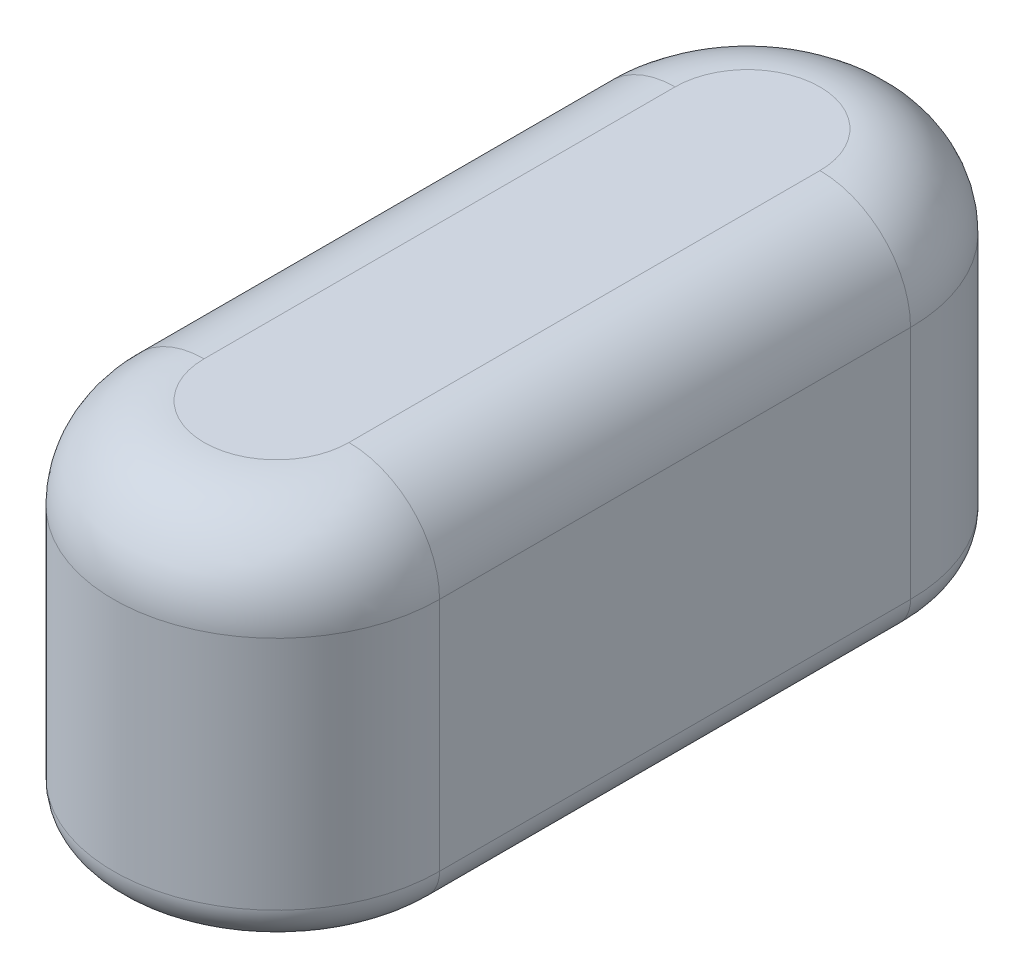
from build123d import *

# Parameters (mm, degrees)
BOSS_EXTRUDE1_DEPTH  = 330.2
REVOLVE1_ANGLE       = 90
MIRROR2_COPY_1_DEPTH = 330.2
MIRROR2_COPY_2_ANGLE = 90


with BuildPart() as part:
    # Sketch1 → Boss-Extrude1 (new body)
    with BuildSketch(Plane.XY):
        with BuildLine():
            Line((0, 12.7), (177.8, 12.7))
            ThreePointArc((177.8, 12.7), (204.740768363, 23.859231637), (215.9, 50.8))
            Line((215.9, 50.8), (215.9, 381))
            ThreePointArc((215.9, 381), (182.42230509, 461.82230509), (101.6, 495.3))
            Line((101.6, 495.3), (0, 495.3))
            Line((0, 495.3), (0, 508))
            Line((0, 508), (101.6, 508))
            ThreePointArc((101.6, 508), (191.402561211, 470.802561211), (228.6, 381))
            Line((228.6, 381), (228.6, 50.8))
            ThreePointArc((228.6, 50.8), (213.721024484, 14.878975516), (177.8, 0))
            Line((177.8, 0), (0, 0))
            Line((0, 0), (0, 12.7))
        make_face()
    boss_extrude1 = extrude(amount=BOSS_EXTRUDE1_DEPTH)

    # Sketch1_2 → Revolve1 (revolve)
    with BuildSketch(Plane.XY):
        with BuildLine():
            Line((0, 12.7), (177.8, 12.7))
            ThreePointArc((177.8, 12.7), (204.740768363, 23.859231637), (215.9, 50.8))
            Line((215.9, 50.8), (215.9, 381))
            ThreePointArc((215.9, 381), (182.42230509, 461.82230509), (101.6, 495.3))
            Line((101.6, 495.3), (0, 495.3))
            Line((0, 495.3), (0, 508))
            Line((0, 508), (101.6, 508))
            ThreePointArc((101.6, 508), (191.402561211, 470.802561211), (228.6, 381))
            Line((228.6, 381), (228.6, 50.8))
            ThreePointArc((228.6, 50.8), (213.721024484, 14.878975516), (177.8, 0))
            Line((177.8, 0), (0, 0))
            Line((0, 0), (0, 12.7))
        make_face()
    revolve1 = revolve(axis=Axis((0, 0, 0), (0, 1, 0)), revolution_arc=REVOLVE1_ANGLE)

    # Mirror1: Boss-Extrude1, Revolve1 across plane
    add(boss_extrude1.mirror(Plane(origin=(0, 0, 0), x_dir=(0, 0, 1), z_dir=(1, 0, 0))))
    add(revolve1.mirror(Plane(origin=(0, 0, 0), x_dir=(0, 0, 1), z_dir=(1, 0, 0))))

    # Mirror2: Boss-Extrude1, Revolve1 across plane
    add(boss_extrude1.mirror(Plane(origin=(177.8, 50.8, 330.2), x_dir=(1, 0, 0), z_dir=(0, 0, 1))))
    add(revolve1.mirror(Plane(origin=(177.8, 50.8, 330.2), x_dir=(1, 0, 0), z_dir=(0, 0, 1))))

    # Mirror2 copy 1 sketch → Mirror2 copy 1 (add)
    with BuildSketch(Plane(origin=(0, 0, 660.4), x_dir=(-1, 0, 0), z_dir=(0, 0, -1))):
        with BuildLine():
            Line((0, 12.7), (177.8, 12.7))
            ThreePointArc((177.8, 12.7), (204.740768363, 23.859231637), (215.9, 50.8))
            Line((215.9, 50.8), (215.9, 381))
            ThreePointArc((215.9, 381), (182.42230509, 461.82230509), (101.6, 495.3))
            Line((101.6, 495.3), (0, 495.3))
            Line((0, 495.3), (0, 508))
            Line((0, 508), (101.6, 508))
            ThreePointArc((101.6, 508), (191.402561211, 470.802561211), (228.6, 381))
            Line((228.6, 381), (228.6, 50.8))
            ThreePointArc((228.6, 50.8), (213.721024484, 14.878975516), (177.8, 0))
            Line((177.8, 0), (0, 0))
            Line((0, 0), (0, 12.7))
        make_face()
    extrude(amount=MIRROR2_COPY_1_DEPTH)

    # Mirror2 copy 2 sketch → Mirror2 copy 2 (revolve)
    with BuildSketch(Plane(origin=(0, 0, 660.4), x_dir=(-1, 0, 0), z_dir=(0, 0, -1))):
        with BuildLine():
            Line((0, 12.7), (177.8, 12.7))
            ThreePointArc((177.8, 12.7), (204.740768363, 23.859231637), (215.9, 50.8))
            Line((215.9, 50.8), (215.9, 381))
            ThreePointArc((215.9, 381), (182.42230509, 461.82230509), (101.6, 495.3))
            Line((101.6, 495.3), (0, 495.3))
            Line((0, 495.3), (0, 508))
            Line((0, 508), (101.6, 508))
            ThreePointArc((101.6, 508), (191.402561211, 470.802561211), (228.6, 381))
            Line((228.6, 381), (228.6, 50.8))
            ThreePointArc((228.6, 50.8), (213.721024484, 14.878975516), (177.8, 0))
            Line((177.8, 0), (0, 0))
            Line((0, 0), (0, 12.7))
        make_face()
    revolve(axis=Axis((0, 0, 660.4), (0, 1, 0)), revolution_arc=MIRROR2_COPY_2_ANGLE)


solid = part.part
